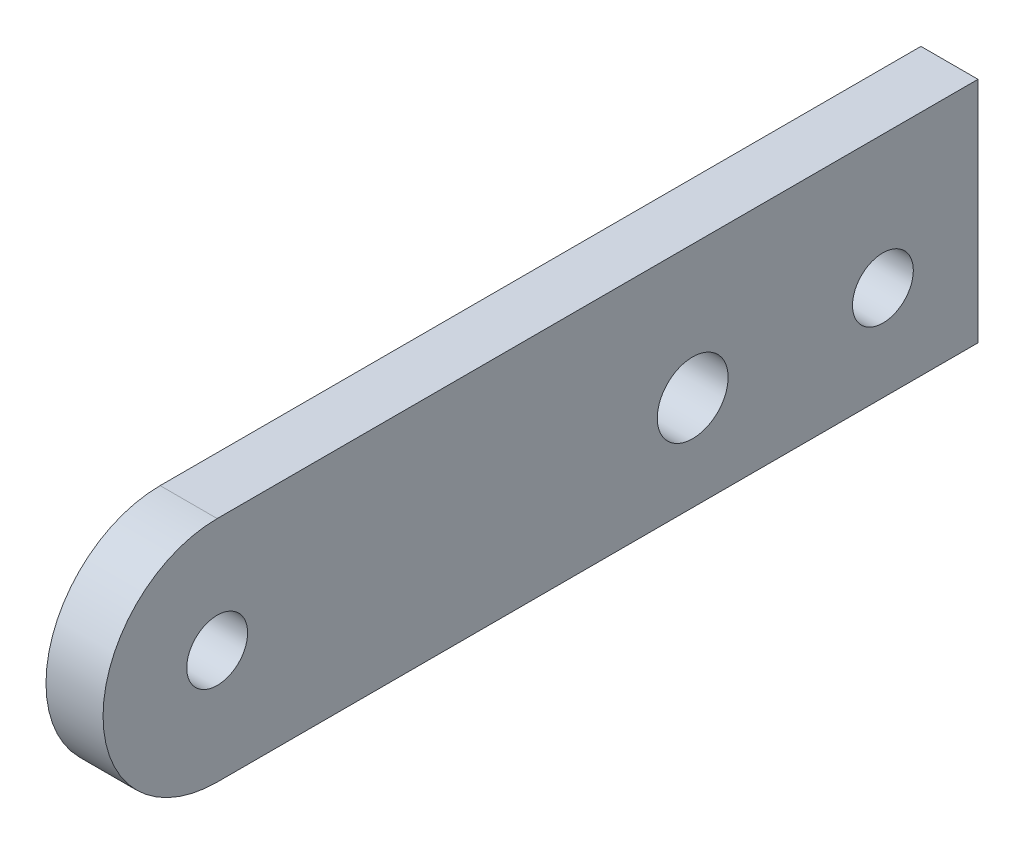
from build123d import *

# Parameters (mm, degrees)
SKETCH1_R           = 1.862815958
SKETCH1_R_2         = 1.6
BOSS_EXTRUDE1_DEPTH = 3


with BuildPart() as part:
    # Sketch1 → Boss-Extrude1 (new body)
    with BuildSketch(Plane(origin=(0, 0, 0), x_dir=(0, 0, -1), z_dir=(1, 0, 0))):
        with BuildLine():
            Line((40, 6), (0, 6))
            ThreePointArc((0, 6), (-6, 0), (0, -6))
            Line((0, -6), (40, -6))
            Line((40, -6), (40, 6))
        make_face()
        with Locations((25, -1)):
            Circle(SKETCH1_R, mode=Mode.SUBTRACT)
        with Locations((35, -1)):
            Circle(SKETCH1_R_2, mode=Mode.SUBTRACT)
        Circle(SKETCH1_R_2, mode=Mode.SUBTRACT)
    extrude(amount=BOSS_EXTRUDE1_DEPTH)


solid = part.part
